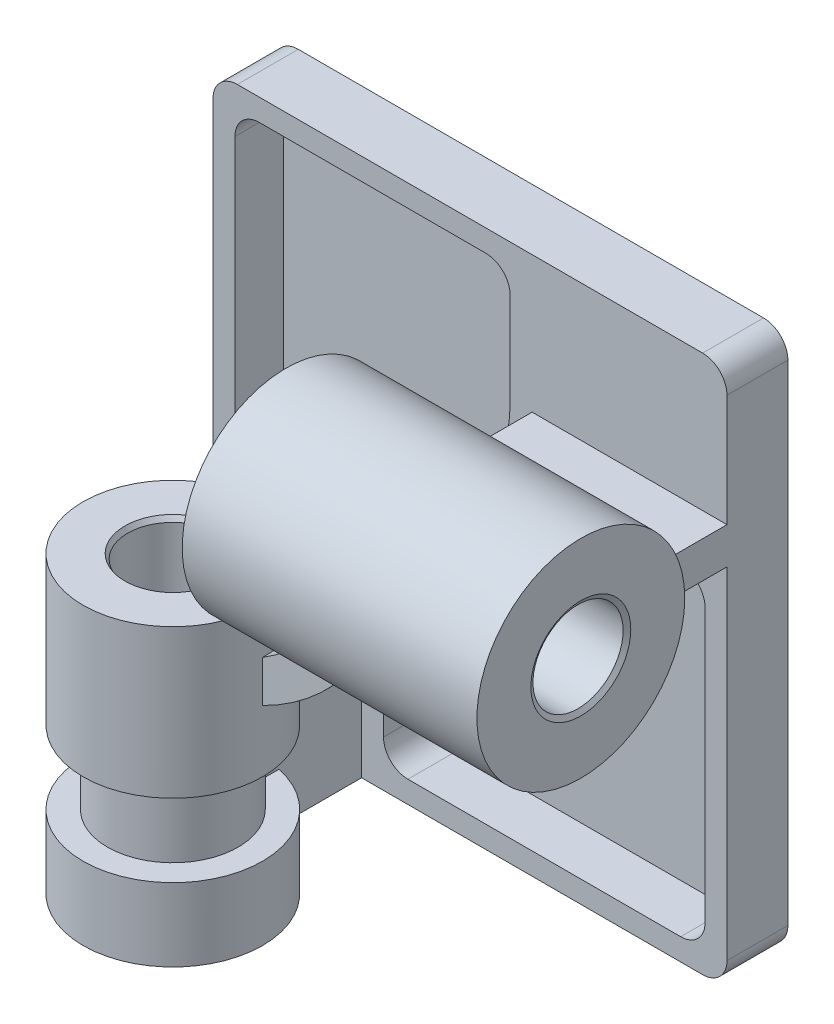
from build123d import *

# Parameters (mm, degrees)
BOSS_EXTRUDE1_DEPTH   = 25
BOSS_EXTRUDE3_DEPTH   = 70
SKETCH7_R             = 36.833333333
BOSS_EXTRUDE4_DEPTH   = 121
SKETCH8_R             = 18.5
CUT_EXTRUDE2_DEPTH    = 232
SKETCH9_R             = 42.666666667
BOSS_EXTRUDE5_DEPTH   = 121
SKETCH10_R            = 18.5
CUT_EXTRUDE3_DEPTH    = 222
CHAMFER1_SIZE         = 2
CHAMFER1_SIZE2        = 1.154700538
CHAMFER1_PART_2_SIZE  = 2
CHAMFER1_PART_2_SIZE2 = 1.154700538
CHAMFER1_PART_3_SIZE  = 2
CHAMFER1_PART_3_SIZE2 = 1.154700538
CHAMFER1_PART_4_SIZE  = 2
CHAMFER1_PART_4_SIZE2 = 1.154700538
CUT_EXTRUDE4_DEPTH    = 20
CUT_EXTRUDE5_DEPTH    = 20
SKETCH16_R            = 36.833333333
SKETCH16_R_2          = 26.833333333
CUT_EXTRUDE7_DEPTH    = 30
BOSS_EXTRUDE7_REACH   = 114.667
SKETCH18_W            = 15
SKETCH18_H            = 30


with BuildPart() as part:
    # Sketch1 → Boss-Extrude1 (new body)
    with BuildSketch(Plane.XY):
        with BuildLine():
            Line((10, 0), (201, 0))
            ThreePointArc((201, 0), (208.071067812, 2.928932188), (211, 10))
            Line((211, 10), (211, 211))
            ThreePointArc((211, 211), (208.071067812, 218.071067812), (201, 221))
            Line((201, 221), (10, 221))
            ThreePointArc((10, 221), (2.928932188, 218.071067812), (0, 211))
            Line((0, 211), (0, 10))
            ThreePointArc((0, 10), (2.928932188, 2.928932188), (10, 0))
        make_face()
    extrude(amount=BOSS_EXTRUDE1_DEPTH)

    # Sketch5 → Boss-Extrude3 (add)
    with BuildSketch(Plane.XY.offset(25)):
        with BuildLine():
            Line((46, 0), (46, 80))
            ThreePointArc((46, 80), (106.104076401, 104.895923599), (131, 165))
            Line((131, 165), (211, 165))
            Line((211, 165), (211, 150))
            Line((211, 150), (144.868599666, 150))
            ThreePointArc((144.868599666, 150), (116.710678119, 94.289321881), (61, 66.131400334))
            Line((61, 66.131400334), (61, 0))
            Line((61, 0), (46, 0))
        make_face()
    extrude(amount=BOSS_EXTRUDE3_DEPTH)

    # Sketch7 → Boss-Extrude4 (add)
    with BuildSketch(Plane(origin=(0, -10, 0), x_dir=(-1, 0, 0), z_dir=(0, -1, 0))):
        with Locations((-53.5, -95)):
            Circle(SKETCH7_R)
    extrude(amount=-BOSS_EXTRUDE4_DEPTH)

    # Sketch8 → Cut-Extrude2 (cut, through all)
    with BuildSketch(Plane.XZ.offset(10)):
        with Locations((53.5, 95)):
            Circle(SKETCH8_R)
    extrude(amount=-CUT_EXTRUDE2_DEPTH, mode=Mode.SUBTRACT)

    # Sketch9 → Boss-Extrude5 (add)
    with BuildSketch(Plane(origin=(221, 0, 0), x_dir=(0, 0, -1), z_dir=(1, 0, 0))):
        with Locations((-95, 157.5)):
            Circle(SKETCH9_R)
    extrude(amount=-BOSS_EXTRUDE5_DEPTH)

    # Sketch10 → Cut-Extrude3 (cut, through all)
    with BuildSketch(Plane(origin=(221, 0, 0), x_dir=(0, 0, -1), z_dir=(1, 0, 0))):
        with Locations((-95, 157.5)):
            Circle(SKETCH10_R)
    extrude(amount=-CUT_EXTRUDE3_DEPTH, mode=Mode.SUBTRACT)

    # Chamfer1
    chamfer1_edges = [part.edges().sort_by_distance(p)[0] for p in [
        (35, 111, 95),
    ]]
    chamfer1_side = [part.faces().sort_by_distance(p)[0] for p in [
        (35, 50.5, 95),
    ]]
    chamfer(chamfer1_edges, length=CHAMFER1_SIZE, length2=CHAMFER1_SIZE2, reference=chamfer1_side[0])

    # Chamfer1 part 2
    chamfer1_part_2_edges = [part.edges().sort_by_distance(p)[0] for p in [
        (35, -10, 95),
    ]]
    chamfer1_part_2_side = [part.faces().sort_by_distance(p)[0] for p in [
        (89.291529342, -10, 95),
    ]]
    chamfer(chamfer1_part_2_edges, length=CHAMFER1_PART_2_SIZE, length2=CHAMFER1_PART_2_SIZE2, reference=chamfer1_part_2_side[0])

    # Chamfer1 part 3
    chamfer1_part_3_edges = [part.edges().sort_by_distance(p)[0] for p in [
        (100, 157.5, 113.5),
    ]]
    chamfer1_part_3_side = [part.faces().sort_by_distance(p)[0] for p in [
        (160.5, 157.5, 113.5),
    ]]
    chamfer(chamfer1_part_3_edges, length=CHAMFER1_PART_3_SIZE, length2=CHAMFER1_PART_3_SIZE2, reference=chamfer1_part_3_side[0])

    # Chamfer1 part 4
    chamfer1_part_4_edges = [part.edges().sort_by_distance(p)[0] for p in [
        (221, 157.5, 113.5),
    ]]
    chamfer1_part_4_side = [part.faces().sort_by_distance(p)[0] for p in [
        (221, 157.5, 136.459871093),
    ]]
    chamfer(chamfer1_part_4_edges, length=CHAMFER1_PART_4_SIZE, length2=CHAMFER1_PART_4_SIZE2, reference=chamfer1_part_4_side[0])

    # Sketch11 → Cut-Extrude4 (cut)
    with BuildSketch(Plane.XY.offset(25)):
        with BuildLine():
            Line((192, 141), (160.039466852, 141))
            ThreePointArc((160.039466852, 141), (154.063323806, 139.017837257), (150.456318377, 133.857142857))
            ThreePointArc((150.456318377, 133.857142857), (123.074639149, 87.925360851), (77.142857143, 60.543681623))
            ThreePointArc((77.142857143, 60.543681623), (71.982162743, 56.936676194), (70, 50.960533148))
            Line((70, 50.960533148), (70, 19))
            ThreePointArc((70, 19), (72.92893248, 11.928931897), (80.000000825, 9))
            Line((80.000000825, 9), (192.000000825, 9.000009238))
            ThreePointArc((192.000000825, 9.000009238), (199.071068103, 11.928941718), (202, 19.000009238))
            Line((202, 19.000009238), (202, 131))
            ThreePointArc((202, 131), (199.071067812, 138.071067812), (192, 141))
        make_face()
    extrude(amount=-CUT_EXTRUDE4_DEPTH, mode=Mode.SUBTRACT)

    # Sketch12 → Cut-Extrude5 (cut)
    with BuildSketch(Plane.XY.offset(25)):
        with BuildLine():
            Line((19, 212), (112, 212))
            ThreePointArc((112, 212), (119.071067812, 209.071067812), (122, 202))
            Line((122, 202), (122, 165))
            ThreePointArc((122, 165), (99.74011537, 111.25988463), (46, 89))
            Line((46, 89), (19, 89))
            ThreePointArc((19, 89), (11.928932188, 91.928932188), (9, 99))
            Line((9, 99), (9, 202))
            ThreePointArc((9, 202), (11.928932188, 209.071067812), (19, 212))
        make_face()
    extrude(amount=-CUT_EXTRUDE5_DEPTH, mode=Mode.SUBTRACT)

    # Sketch16 → Cut-Extrude7 (cut)
    with BuildSketch(Plane(origin=(0, 20, 0), x_dir=(-1, 0, 0), z_dir=(0, -1, 0))):
        with Locations((-53.5, -95)):
            Circle(SKETCH16_R)
        with Locations((-53.5, -95)):
            Circle(SKETCH16_R_2, mode=Mode.SUBTRACT)
    extrude(amount=-CUT_EXTRUDE7_DEPTH, mode=Mode.SUBTRACT)

    # Sketch18 → Boss-Extrude7 (add, up to next)
    with BuildSketch(Plane.XY.offset(25), mode=Mode.PRIVATE) as boss_extrude7_sk1:
        with Locations((53.5, 35)):
            Rectangle(SKETCH18_W, SKETCH18_H)
    boss_extrude7_tool1 = extrude(boss_extrude7_sk1.sketch, amount=BOSS_EXTRUDE7_REACH, mode=Mode.PRIVATE) - part.part
    add(boss_extrude7_tool1.solids().sort_by_distance((53.5, 35, 25))[0])


solid = part.part
